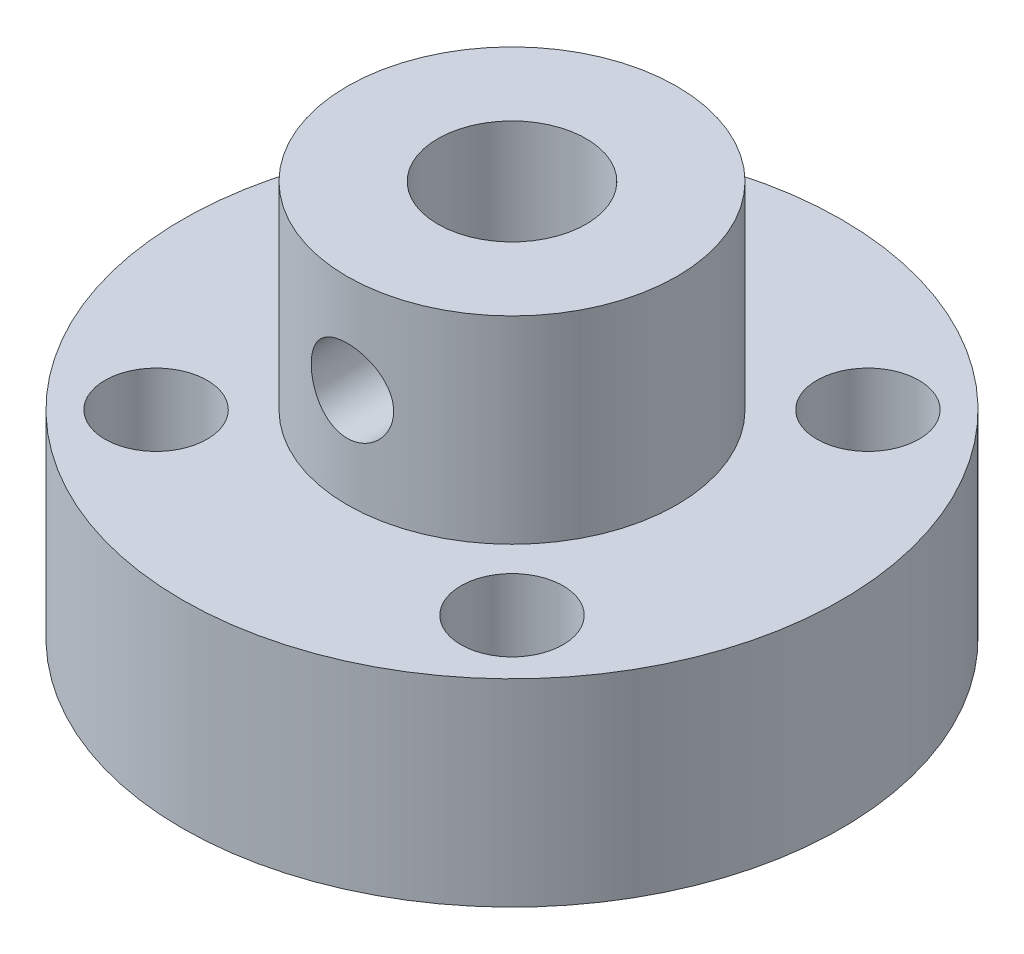
from build123d import *

# Parameters (mm, degrees)
SKIZZE1_R                       = 10
AUFSATZ_LINEAR_AUSTRAGEN1_DEPTH = 6
SKIZZE2_R                       = 5
AUFSATZ_LINEAR_AUSTRAGEN2_DEPTH = 6
SKIZZE3_R                       = 2.25
SCHNITT_LINEAR_AUSTRAGEN1_DEPTH = 9
SKIZZE4_R                       = 1.55
SCHNITT_LINEAR_AUSTRAGEN2_DEPTH = 7
SCHNITT_LINEAR_AUSTRAGEN3_REACH = 17
SKIZZE5_R                       = 1.25


with BuildPart() as part:
    # Skizze1 → Aufsatz-Linear austragen1 (new body)
    with BuildSketch(Plane(origin=(0, 0, 0), x_dir=(1, 0, 0), z_dir=(0, 1, 0))):
        Circle(SKIZZE1_R)
    extrude(amount=AUFSATZ_LINEAR_AUSTRAGEN1_DEPTH)

    # Skizze2 → Aufsatz-Linear austragen2 (add)
    with BuildSketch(Plane(origin=(0, 6, 0), x_dir=(1, 0, 0), z_dir=(0, 1, 0))):
        Circle(SKIZZE2_R)
    extrude(amount=AUFSATZ_LINEAR_AUSTRAGEN2_DEPTH)

    # Skizze3 → Schnitt-Linear austragen1 (cut)
    with BuildSketch(Plane(origin=(0, 12, 0), x_dir=(1, 0, 0), z_dir=(0, 1, 0))):
        Circle(SKIZZE3_R)
    extrude(amount=-SCHNITT_LINEAR_AUSTRAGEN1_DEPTH, mode=Mode.SUBTRACT)

    # Skizze4 → Schnitt-Linear austragen2 (cut, through all)
    with BuildSketch(Plane(origin=(0, 6, 0), x_dir=(1, 0, 0), z_dir=(0, 1, 0))):
        with Locations((-5.4, 5.4)):
            Circle(SKIZZE4_R)
        with Locations((5.4, 5.4)):
            Circle(SKIZZE4_R)
        with Locations((5.4, -5.4)):
            Circle(SKIZZE4_R)
        with Locations((-5.4, -5.4)):
            Circle(SKIZZE4_R)
    extrude(amount=-SCHNITT_LINEAR_AUSTRAGEN2_DEPTH, mode=Mode.SUBTRACT)

    # Skizze5 → Schnitt-Linear austragen3 (cut, up to next)
    with BuildSketch(Plane.XY.offset(5), mode=Mode.PRIVATE) as schnitt_linear_austragen3_sk1:
        with Locations((0, 9)):
            Circle(SKIZZE5_R)
    schnitt_linear_austragen3_tool1 = extrude(schnitt_linear_austragen3_sk1.sketch, amount=-SCHNITT_LINEAR_AUSTRAGEN3_REACH, mode=Mode.PRIVATE) & part.part
    add(schnitt_linear_austragen3_tool1.solids().sort_by_distance((0, 9, 5))[0], mode=Mode.SUBTRACT)


solid = part.part
